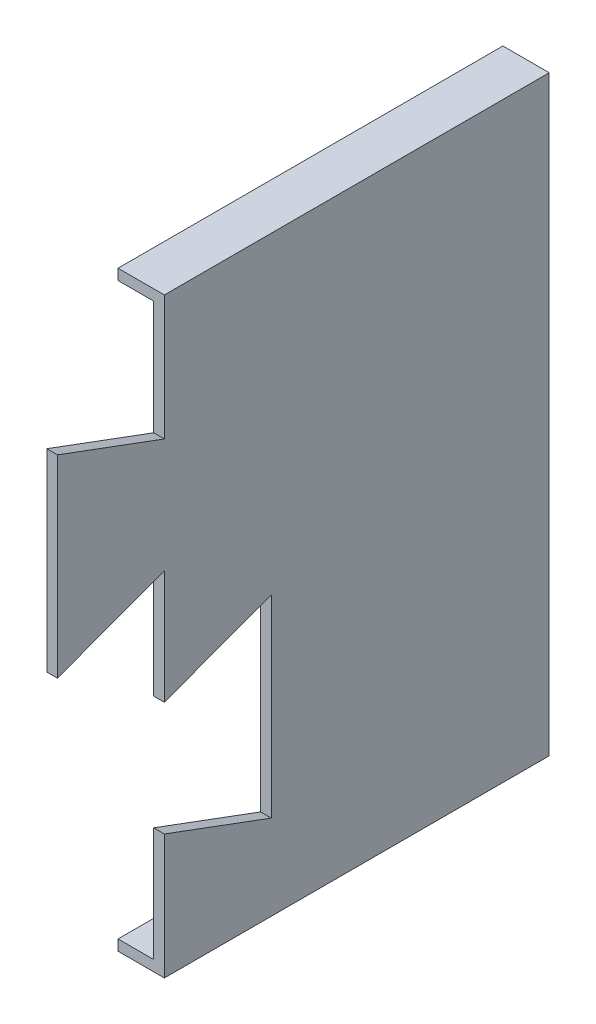
from build123d import *

# Parameters (mm, degrees)
SKETCH_1_W          = 13
SKETCH_1_H          = 160
EXTRUDE_1_DEPTH     = 3
SKETCH_2_W          = 3
SKETCH_2_H          = 160
EXTRUDE_2_DEPTH     = 135
SKETCH_3_W          = 13
SKETCH_3_H          = 138
EXTRUDE_3_DEPTH     = 3
SKETCH_4_W          = 13
SKETCH_4_H          = 138
EXTRUDE_4_DEPTH     = 3
CUT_EXTRUDE_1_DEPTH = 14


with BuildPart() as part:
    # 草圖1 → 填料-伸長1 (new body)
    with BuildSketch(Plane.XY):
        with Locations((-15.144058005, -60.964912281)):
            Rectangle(SKETCH_1_W, SKETCH_1_H)
    extrude(amount=EXTRUDE_1_DEPTH)

    # 草圖2 → 填料-伸長2 (add)
    with BuildSketch(Plane.XY.offset(3)):
        with Locations((-10.144058005, -60.964912281)):
            Rectangle(SKETCH_2_W, SKETCH_2_H)
    extrude(amount=EXTRUDE_2_DEPTH)

    # 草圖3 → 填料-伸長3 (add)
    with BuildSketch(Plane.XZ.offset(140.964912281)):
        with Locations((-15.144058005, 69)):
            Rectangle(SKETCH_3_W, SKETCH_3_H)
    extrude(amount=EXTRUDE_3_DEPTH)

    # 草圖4 → 填料-伸長4 (add)
    with BuildSketch(Plane(origin=(0, 19.035087719, 0), x_dir=(1, 0, 0), z_dir=(0, 1, 0))):
        with Locations((-15.144058005, -69)):
            Rectangle(SKETCH_4_W, SKETCH_4_H)
    extrude(amount=EXTRUDE_4_DEPTH)

    # 草圖5 → 除料-伸長1 (cut, through all)
    with BuildSketch(Plane(origin=(-8.644058005, 0, 0), x_dir=(0, 0, -1), z_dir=(1, 0, 0))):
        Polygon((-108, -76.964912281), (-108, -44.964912281), (-138, -56.100441006), (-138, -143.964912281), (-108, -143.964912281), (-108, -108.964912281), (-77.999803751, -120.099912281), (-77.999803751, -65.829912281), align=None)
        Polygon((-138, 22.035087719), (-138, -1.829383555), (-108, -12.964912281), (-108, 22.035087719), align=None)
    extrude(amount=-CUT_EXTRUDE_1_DEPTH, mode=Mode.SUBTRACT)


solid = part.part
